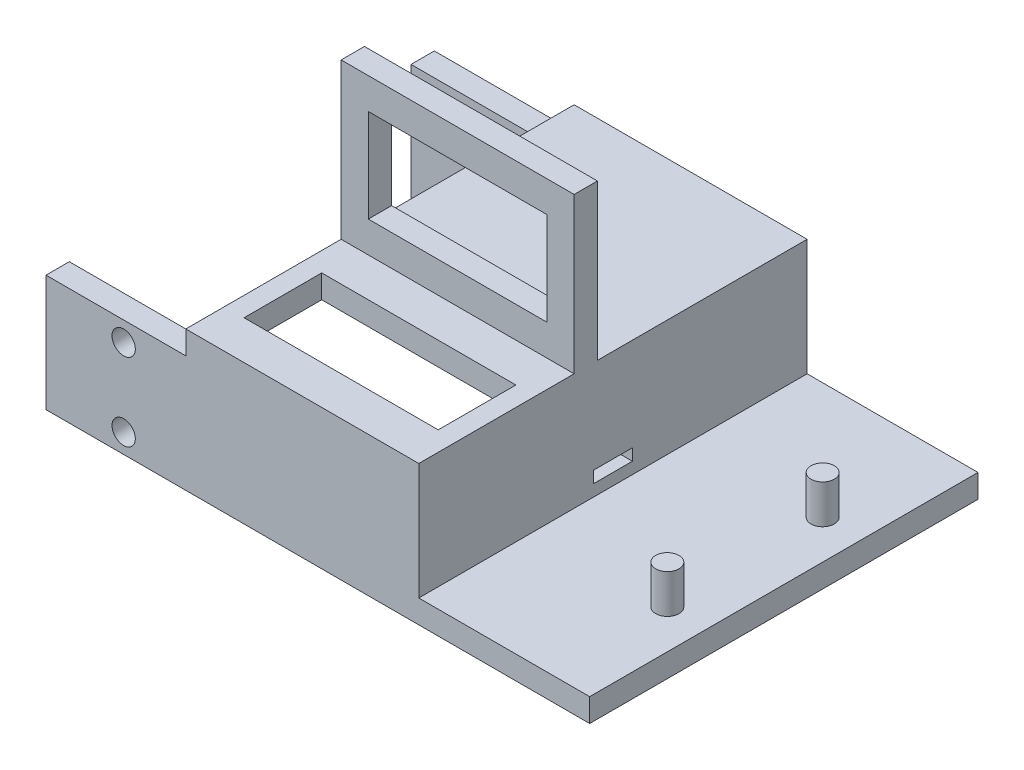
from build123d import *

# Parameters (mm, degrees)
BOSS_EXTRUDE1_DEPTH     = 50
SKETCH2_R               = 1.5
BOSS_EXTRUDE2_DEPTH     = 5
SKETCH3_W               = 5
SKETCH3_H               = 1.5
CUT_EXTRUDE1_DEPTH      = 58.879184514
CUT_EXTRUDE1_DEPTH_BACK = 58.879184514
SKETCH4_W               = 45
SKETCH4_H               = 15
BOSS_EXTRUDE3_DEPTH     = 3
SKETCH5_W               = 45
SKETCH5_H               = 15
BOSS_EXTRUDE4_DEPTH     = 3
SKETCH6_R               = 1.5
CUT_EXTRUDE2_DEPTH      = 69.92024376
CUT_EXTRUDE2_DEPTH_BACK = 69.92024376
SKETCH8_W               = 30
SKETCH8_H               = 50
SKETCH8_W_2             = 25
SKETCH8_H_2             = 10
BOSS_EXTRUDE7_DEPTH     = 3
SERVO_MOUNT_DEPTH       = 3


with BuildPart() as part:
    # Sketch1 → Boss-Extrude1 (new body)
    with BuildSketch(Plane.XY):
        Polygon((0, 0), (25, 0), (25, 3), (3, 3), (3, 15), (0, 15), align=None)
    extrude(amount=BOSS_EXTRUDE1_DEPTH)

    # Sketch2 → Boss-Extrude2 (add)
    with BuildSketch(Plane(origin=(0, 3, 0), x_dir=(1, 0, 0), z_dir=(0, 1, 0))):
        with Locations((20, -15)):
            Circle(SKETCH2_R)
        with Locations((20, -35)):
            Circle(SKETCH2_R)
    extrude(amount=BOSS_EXTRUDE2_DEPTH)

    # Sketch3 → Cut-Extrude1 (cut, two sides)
    with BuildSketch(Plane.ZY) as cut_extrude1_sk:
        with Locations((25, 5.25)):
            Rectangle(SKETCH3_W, SKETCH3_H)
    extrude(amount=CUT_EXTRUDE1_DEPTH, mode=Mode.SUBTRACT)
    extrude(cut_extrude1_sk.sketch, amount=-CUT_EXTRUDE1_DEPTH_BACK, mode=Mode.SUBTRACT)

    # Sketch4 → Boss-Extrude3 (add)
    with BuildSketch(Plane(origin=(0, 0, 0), x_dir=(-1, 0, 0), z_dir=(0, 0, -1))):
        with Locations((22.5, 7.5)):
            Rectangle(SKETCH4_W, SKETCH4_H)
    extrude(amount=-BOSS_EXTRUDE3_DEPTH)

    # Sketch5 → Boss-Extrude4 (add)
    with BuildSketch(Plane.XY.offset(50)):
        with Locations((-22.5, 7.5)):
            Rectangle(SKETCH5_W, SKETCH5_H)
    extrude(amount=-BOSS_EXTRUDE4_DEPTH)

    # Sketch6 → Cut-Extrude2 (cut, two sides)
    with BuildSketch(Plane.XY.offset(50)) as cut_extrude2_sk:
        with Locations((-35, 12.5)):
            Circle(SKETCH6_R)
        with Locations((-35, 2.5)):
            Circle(SKETCH6_R)
    extrude(amount=CUT_EXTRUDE2_DEPTH, mode=Mode.SUBTRACT)
    extrude(cut_extrude2_sk.sketch, amount=-CUT_EXTRUDE2_DEPTH_BACK, mode=Mode.SUBTRACT)

    # Sketch8 → Boss-Extrude7 (add)
    with BuildSketch(Plane(origin=(0, 15, 0), x_dir=(1, 0, 0), z_dir=(0, 1, 0))):
        with Locations((-12, -25)):
            Rectangle(SKETCH8_W, SKETCH8_H)
        with Locations((-12, -40)):
            Rectangle(SKETCH8_W_2, SKETCH8_H_2, mode=Mode.SUBTRACT)
    extrude(amount=BOSS_EXTRUDE7_DEPTH)

    # 3DSketch1 → servo mount (add)
    with BuildSketch(Plane(origin=(-27, 18, 30), x_dir=(0.8320502943378437, 0.5547001962252291, 0), z_dir=(0, 0, -1))):
        Polygon((0, 0), (24.96150883, 16.641005887), (36.055512755, 0), (11.094003925, -16.641005887), align=None)
        Polygon((11.78737917, -11.371354023), (30.92453594, 1.386750491), (24.268133585, 11.371354023), (5.130976815, -1.386750491), align=None, mode=Mode.SUBTRACT)
    extrude(amount=SERVO_MOUNT_DEPTH)


solid = part.part
